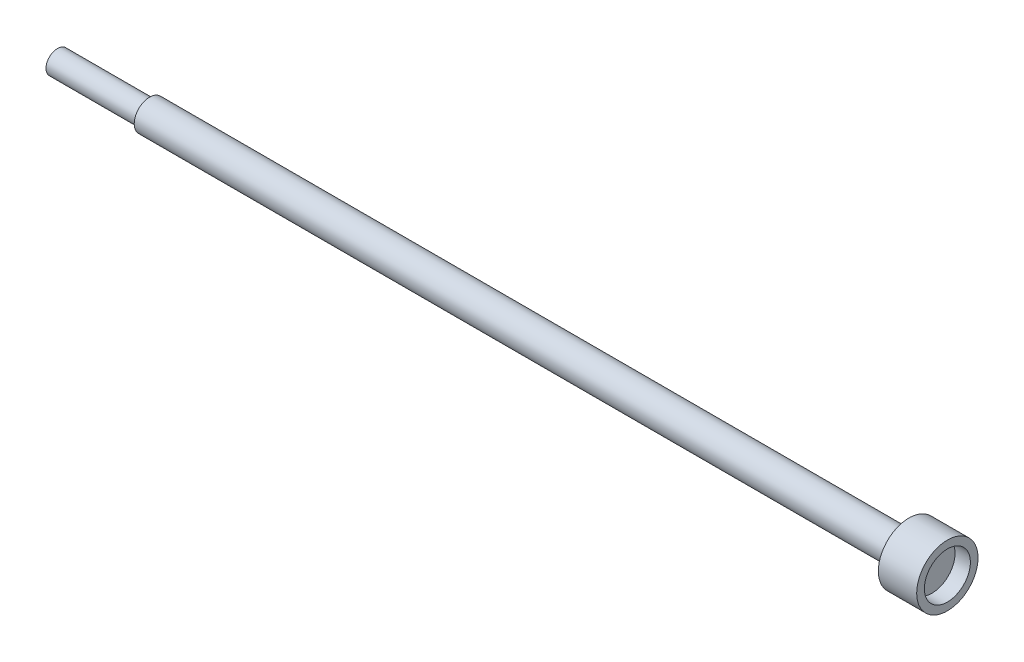
from build123d import *

# Parameters (mm, degrees)
SKETCH3_W               = 25.4
SKETCH3_H               = 3.175
CUT_EXTRUDE1_DEPTH      = 725.790680128
CUT_EXTRUDE1_DEPTH_BACK = 725.790680128


with BuildPart() as part:
    # Sketch2 → Revolve1 (revolve)
    with BuildSketch(Plane(origin=(0, 0, 0), x_dir=(1, 0, 0), z_dir=(0, 1, 0)), mode=Mode.PRIVATE) as revolve1_sk:
        Polygon((-723.9, 0), (0, 0), (0, 19.05), (12.7, 19.05), (12.7, 25.4), (-19.05, 25.4), (-19.05, 12.7), (-647.7, 12.7), (-647.7, 9.525), (-723.9, 9.525), align=None)
    revolve(revolve1_sk.sketch.rotate(Axis((-723.9, 0, 0), (1, 0, 0)), 180), axis=Axis((-723.9, 0, 0), (1, 0, 0)))

    # Sketch3 → Cut-Extrude1 (cut, two sides)
    with BuildSketch(Plane(origin=(0, 0, 0), x_dir=(1, 0, 0), z_dir=(0, 1, 0))) as cut_extrude1_sk:
        with Locations((-411.48, 11.1125)):
            Rectangle(SKETCH3_W, SKETCH3_H)
    extrude(amount=CUT_EXTRUDE1_DEPTH, mode=Mode.SUBTRACT)
    extrude(cut_extrude1_sk.sketch, amount=-CUT_EXTRUDE1_DEPTH_BACK, mode=Mode.SUBTRACT)


solid = part.part
